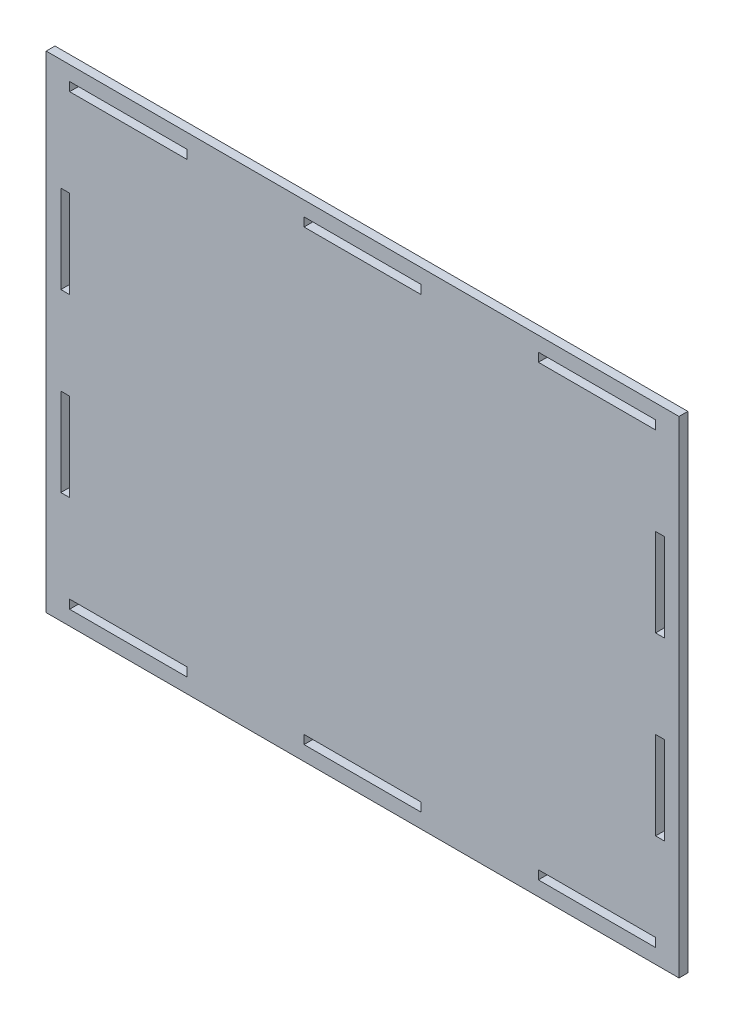
from build123d import *

# Parameters (mm, degrees)
SKETCH1_W           = 216
SKETCH1_H           = 166
SKETCH1_W_2         = 40
SKETCH1_H_2         = 3
SKETCH1_W_3         = 3
SKETCH1_H_3         = 30
BOSS_EXTRUDE1_DEPTH = 3


with BuildPart() as part:
    # Sketch1 → Boss-Extrude1 (new body)
    with BuildSketch(Plane.XY):
        Rectangle(SKETCH1_W, SKETCH1_H)
        with Locations((-80, 76.5)):
            Rectangle(SKETCH1_W_2, SKETCH1_H_2, mode=Mode.SUBTRACT)
        with Locations((80, 76.5)):
            Rectangle(SKETCH1_W_2, SKETCH1_H_2, mode=Mode.SUBTRACT)
        with Locations((101.5, 30)):
            Rectangle(SKETCH1_W_3, SKETCH1_H_3, mode=Mode.SUBTRACT)
        with Locations((80, -76.5)):
            Rectangle(SKETCH1_W_2, SKETCH1_H_2, mode=Mode.SUBTRACT)
        with Locations((-101.5, 30)):
            Rectangle(SKETCH1_W_3, SKETCH1_H_3, mode=Mode.SUBTRACT)
        with Locations((0, 76.5)):
            Rectangle(SKETCH1_W_2, SKETCH1_H_2, mode=Mode.SUBTRACT)
        with Locations((101.5, -30)):
            Rectangle(SKETCH1_W_3, SKETCH1_H_3, mode=Mode.SUBTRACT)
        with Locations((0, -76.5)):
            Rectangle(SKETCH1_W_2, SKETCH1_H_2, mode=Mode.SUBTRACT)
        with Locations((-80, -76.5)):
            Rectangle(SKETCH1_W_2, SKETCH1_H_2, mode=Mode.SUBTRACT)
        with Locations((-101.5, -30)):
            Rectangle(SKETCH1_W_3, SKETCH1_H_3, mode=Mode.SUBTRACT)
    extrude(amount=BOSS_EXTRUDE1_DEPTH)


solid = part.part
